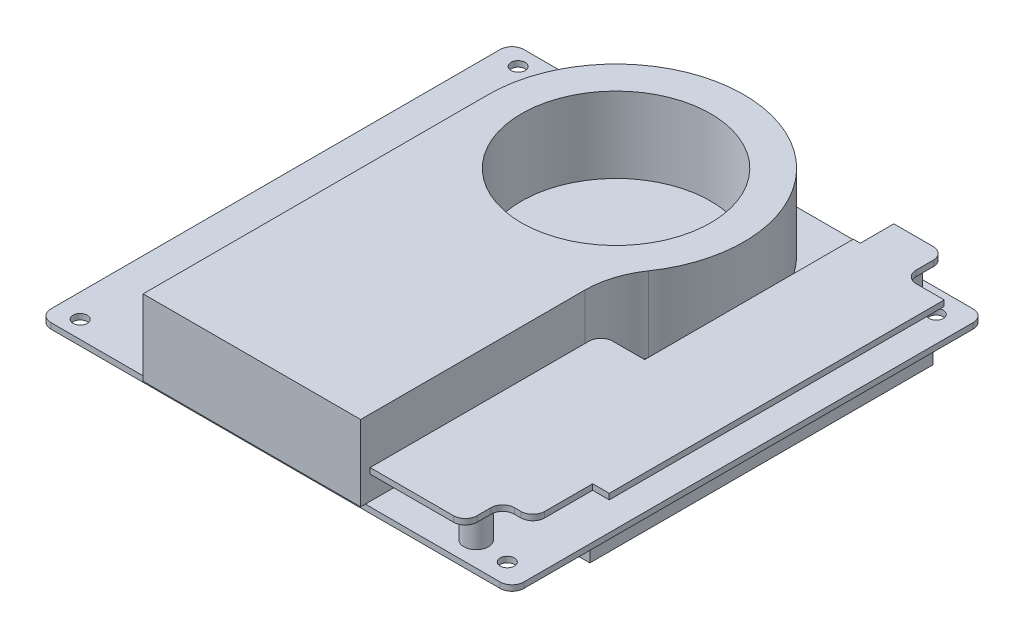
from build123d import *

# Parameters (mm, degrees)
SKETCH1_R           = 1.5
BOSS_EXTRUDE1_DEPTH = 1.2
SKETCH2_W           = 29.840930046
SKETCH2_H           = 54.765276652
BOSS_EXTRUDE2_DEPTH = 7
SKETCH3_W           = 33.788082064
SKETCH3_H           = 72.581353001
BOSS_EXTRUDE3_DEPTH = 5.5
SKETCH4_R           = 20
BOSS_EXTRUDE4_DEPTH = 16
SKETCH5_R           = 2.6
BOSS_EXTRUDE5_DEPTH = 6
BOSS_EXTRUDE6_DEPTH = 1.2
FILLET1_R           = 2.5


with BuildPart() as part:
    # Sketch1 → Boss-Extrude1 (new body)
    with BuildSketch(Plane(origin=(0, 0, 0), x_dir=(1, 0, 0), z_dir=(0, 1, 0))):
        with BuildLine():
            Line((2.5, 100), (97.5, 100))
            ThreePointArc((97.5, 100), (99.267766953, 99.267766953), (100, 97.5))
            Line((100, 97.5), (100, 2.5))
            ThreePointArc((100, 2.5), (99.267766953, 0.732233047), (97.5, 0))
            Line((97.5, 0), (2.5, 0))
            ThreePointArc((2.5, 0), (0.732233047, 0.732233047), (0, 2.5))
            Line((0, 2.5), (0, 97.5))
            ThreePointArc((0, 97.5), (0.732233047, 99.267766953), (2.5, 100))
        make_face()
        with Locations((5, 96.3)):
            Circle(SKETCH1_R, mode=Mode.SUBTRACT)
        with Locations((94.6, 95.1)):
            Circle(SKETCH1_R, mode=Mode.SUBTRACT)
        with Locations((5, 3.7)):
            Circle(SKETCH1_R, mode=Mode.SUBTRACT)
        with Locations((94.6, 4.4)):
            Circle(SKETCH1_R, mode=Mode.SUBTRACT)
    extrude(amount=BOSS_EXTRUDE1_DEPTH)

    # Sketch2 → Boss-Extrude2 (add)
    with BuildSketch(Plane.XZ):
        with Locations((36.983095354, -49.21487939)):
            Rectangle(SKETCH2_W, SKETCH2_H)
    extrude(amount=BOSS_EXTRUDE2_DEPTH)

    # Sketch3 → Boss-Extrude3 (add)
    with BuildSketch(Plane.XZ):
        with Locations((79.907693041, -55.955425872)):
            Rectangle(SKETCH3_W, SKETCH3_H)
    extrude(amount=BOSS_EXTRUDE3_DEPTH)

    # Sketch4 → Boss-Extrude4 (add)
    with BuildSketch(Plane(origin=(0, 1.2, 0), x_dir=(1, 0, 0), z_dir=(0, 1, 0))):
        with BuildLine():
            Line((23, -1), (23, 72))
            ThreePointArc((23, 72), (58.049844719, 97.772077914), (72.2, 56.63250183))
            ThreePointArc((72.2, 56.63250183), (69.818614724, 51.754066196), (69, 46.38750305))
            Line((69, 46.38750305), (69, -1))
            Line((69, -1), (23, -1))
        make_face()
        with Locations((50, 72)):
            Circle(SKETCH4_R, mode=Mode.SUBTRACT)
    extrude(amount=BOSS_EXTRUDE4_DEPTH)

    # Sketch5 → Boss-Extrude5 (add)
    with BuildSketch(Plane(origin=(0, 1.2, 0), x_dir=(1, 0, 0), z_dir=(0, 1, 0))):
        with Locations((87.841987056, 95.287894157)):
            Circle(SKETCH5_R)
        with Locations((87.226934535, 5.201319217)):
            Circle(SKETCH5_R)
    extrude(amount=BOSS_EXTRUDE5_DEPTH)

    # Sketch6 → Boss-Extrude6 (add)
    with BuildSketch(Plane(origin=(0, 7.2, 0), x_dir=(1, 0, 0), z_dir=(0, 1, 0))):
        Polygon((80.739794291, 100), (80.739794291, 92.907164266), (79.266881022, 92.907164266), (79.266881022, 48.78574174), (70, 48.78574174), (70, 0), (90.117817522, 0), (90.117817522, 7.917821809), (96.488136969, 7.917821809), (96.488136969, 20.556535591), (100, 20.556535591), (100, 91.38711124), (91.568142489, 91.38711124), (91.568142489, 100), align=None)
    extrude(amount=BOSS_EXTRUDE6_DEPTH)

    # Fillet1
    fillet1_edges = [part.edges().sort_by_distance(p)[0] for p in [
        (90.117817522, 7.8, -7.917821809),
        (96.488136969, 7.8, -7.917821809),
        (91.568142489, 7.8, -91.38711124),
        (91.568142489, 7.8, -100),
        (70, 7.8, -48.78574174),
        (90.117817522, 7.8, 0),
    ]]
    fillet(fillet1_edges, radius=FILLET1_R)


solid = part.part
